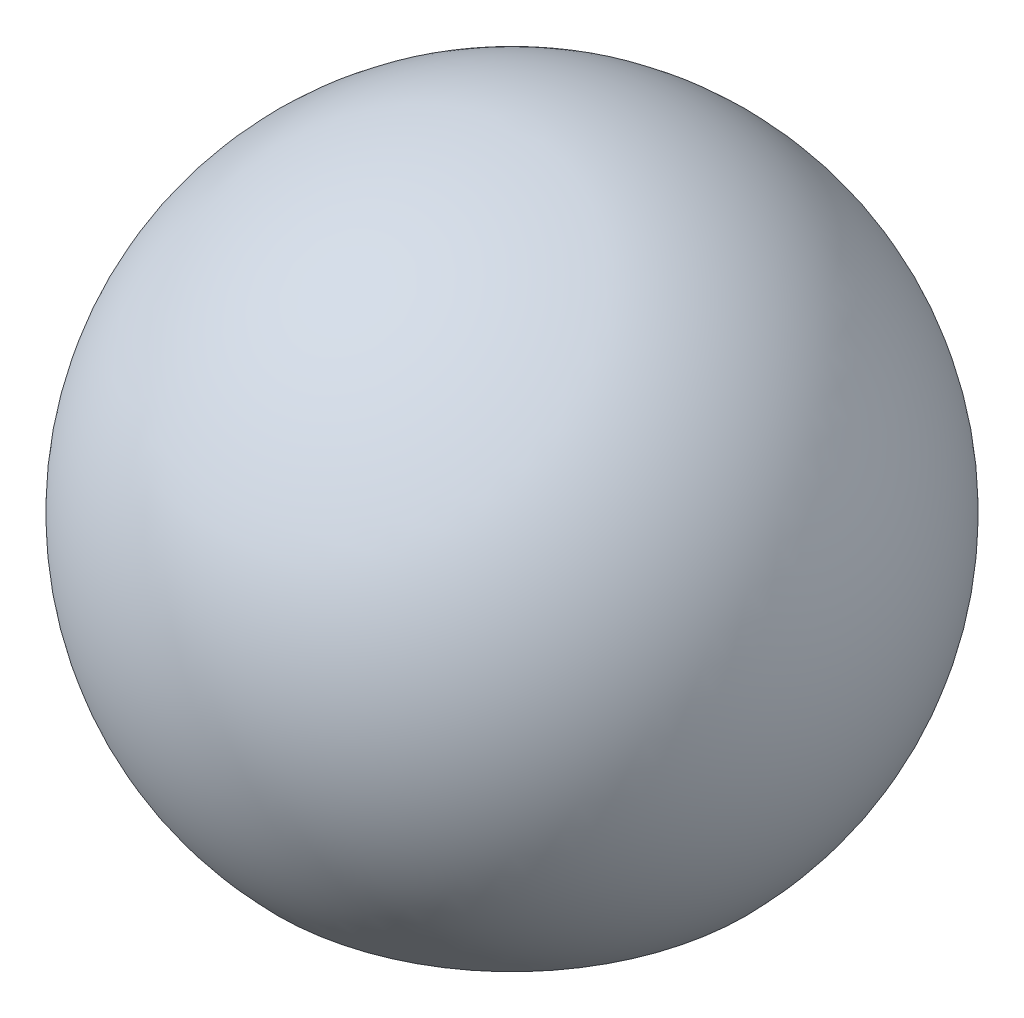
from build123d import *


with BuildPart() as part:
    # Sketch2 → Revolve1 (revolve)
    with BuildSketch(Plane.XY):
        with BuildLine():
            Line((0, 1100), (0, 900))
            ThreePointArc((0, 900), (369.190544784, 653.942656993), (284.170867004, 218.491708211))
            Line((284.170867004, 218.491708211), (426.256300507, 77.737562316))
            ThreePointArc((426.256300507, 77.737562316), (553.785817176, 730.91398549), (0, 1100))
        make_face()
    revolve(axis=Axis((0, 1129.36353187, 0), (0, -1, 0)))


solid = part.part
